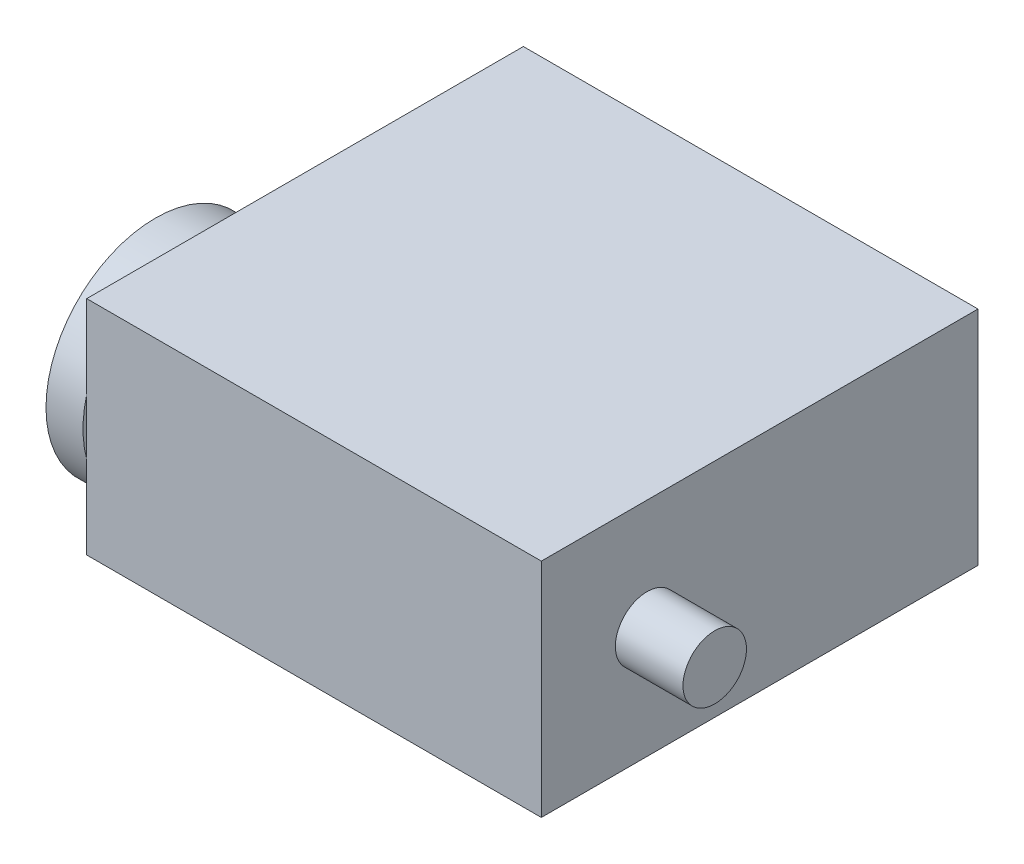
from build123d import *

# Parameters (mm, degrees)
SKETCH_1_W          = 43
SKETCH_1_H          = 21
EXTRUDE_1_DEPTH     = 41.3
SKETCH_2_R          = 3
EXTRUDE_2_DEPTH     = 6.4
SKETCH_3_R          = 10.35
EXTRUDE_3_DEPTH     = 3.5
SKETCH_4_R          = 6
EXTRUDE_4_DEPTH     = 1.5
SKETCH_5_R          = 0.75
CUT_EXTRUDE_1_DEPTH = 4


with BuildPart() as part:
    # 草图1 → 凸台-拉伸1 (new body)
    with BuildSketch(Plane.XY):
        Rectangle(SKETCH_1_W, SKETCH_1_H)
    extrude(amount=EXTRUDE_1_DEPTH)

    # 草图2 → 凸台-拉伸2 (add)
    with BuildSketch(Plane(origin=(21.5, 0, 0), x_dir=(0, 0, -1), z_dir=(1, 0, 0))):
        with Locations((-31.3, 0)):
            Circle(SKETCH_2_R)
    extrude(amount=EXTRUDE_2_DEPTH)

    # 草图3 → 凸台-拉伸3 (add)
    with BuildSketch(Plane.ZY.offset(21.5)):
        with Locations((31.3, 0)):
            Circle(SKETCH_3_R)
    extrude(amount=EXTRUDE_3_DEPTH)

    # 草图4 → 凸台-拉伸4 (add)
    with BuildSketch(Plane.ZY.offset(25)):
        with Locations((31.3, 0)):
            Circle(SKETCH_4_R)
    extrude(amount=EXTRUDE_4_DEPTH)

    # 草图5 → 切除-拉伸1 (cut)
    with BuildSketch(Plane.ZY.offset(25)):
        with Locations((38.75, 0)):
            Circle(SKETCH_5_R)
        with Locations((31.3, -7.45)):
            Circle(SKETCH_5_R)
        with Locations((23.85, 0)):
            Circle(SKETCH_5_R)
        with Locations((31.3, 7.45)):
            Circle(SKETCH_5_R)
    extrude(amount=-CUT_EXTRUDE_1_DEPTH, mode=Mode.SUBTRACT)


solid = part.part
